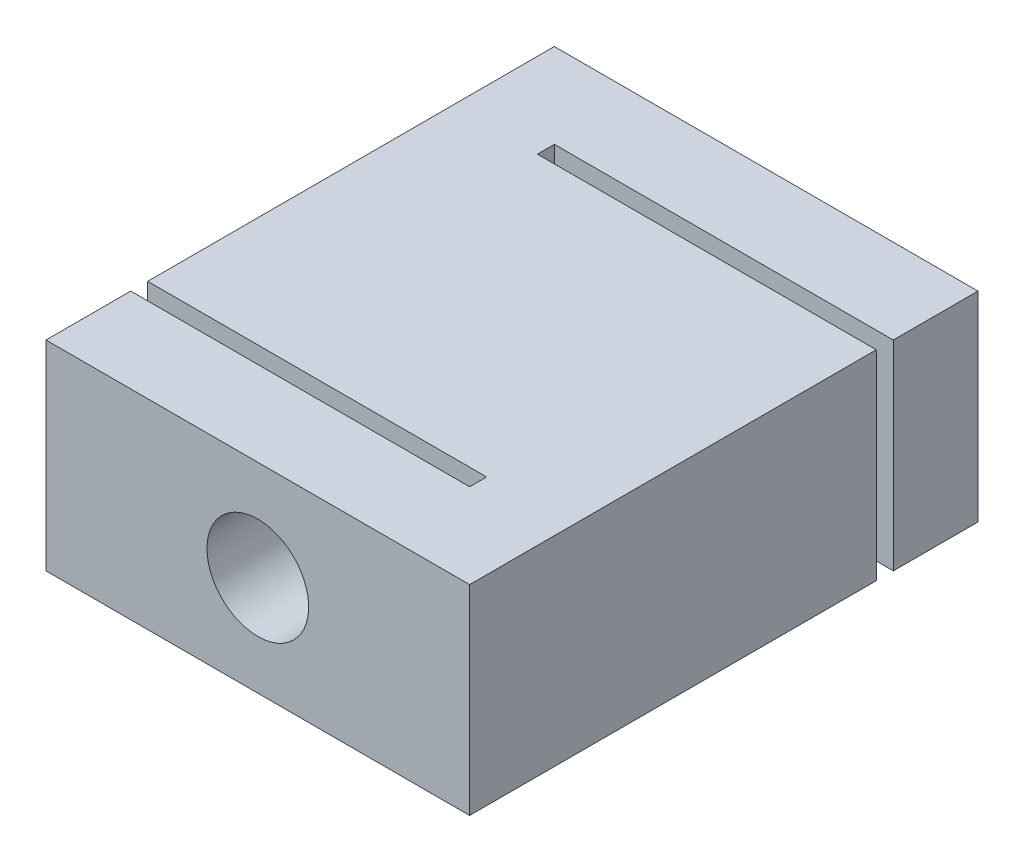
from build123d import *

# Parameters (mm, degrees)
SKETCH_1_W          = 25
SKETCH_1_H          = 30
EXTRUDE_1_DEPTH     = 11.8
SKETCH_2_W          = 20
SKETCH_2_H          = 1
CUT_EXTRUDE_1_DEPTH = 13.5
CUT_EXTRUDE_2_DEPTH = 30


with BuildPart() as part:
    # 草图1 → 凸台-拉伸1 (new body)
    with BuildSketch(Plane(origin=(0, 0, 0), x_dir=(1, 0, 0), z_dir=(0, 1, 0))):
        with Locations((12.5, 15)):
            Rectangle(SKETCH_1_W, SKETCH_1_H)
    extrude(amount=EXTRUDE_1_DEPTH)

    # 草图2 → 切除-拉伸1 (cut)
    with BuildSketch(Plane(origin=(0, 11.8, 0), x_dir=(1, 0, 0), z_dir=(0, 1, 0))):
        with Locations((15, 24.5)):
            Rectangle(SKETCH_2_W, SKETCH_2_H)
        with Locations((10, 5.5)):
            Rectangle(SKETCH_2_W, SKETCH_2_H)
    extrude(amount=-CUT_EXTRUDE_1_DEPTH, mode=Mode.SUBTRACT)

    # 草图3 → 切除-拉伸2 (cut)
    with BuildSketch(Plane(origin=(0, 0, -30), x_dir=(-1, 0, 0), z_dir=(0, 0, -1))):
        with BuildLine():
            ThreePointArc((-9.5, 5.9), (-10.378679656, 8.021320344), (-12.5, 8.9))
            Line((-12.5, 8.9), (-12.5, 2.9))
            ThreePointArc((-12.5, 2.9), (-10.378679656, 3.778679656), (-9.5, 5.9))
        make_face()
        with BuildLine():
            Line((-12.5, 2.9), (-12.5, 8.9))
            ThreePointArc((-12.5, 8.9), (-15.5, 5.9), (-12.5, 2.9))
        make_face()
    extrude(amount=-CUT_EXTRUDE_2_DEPTH, mode=Mode.SUBTRACT)


solid = part.part
